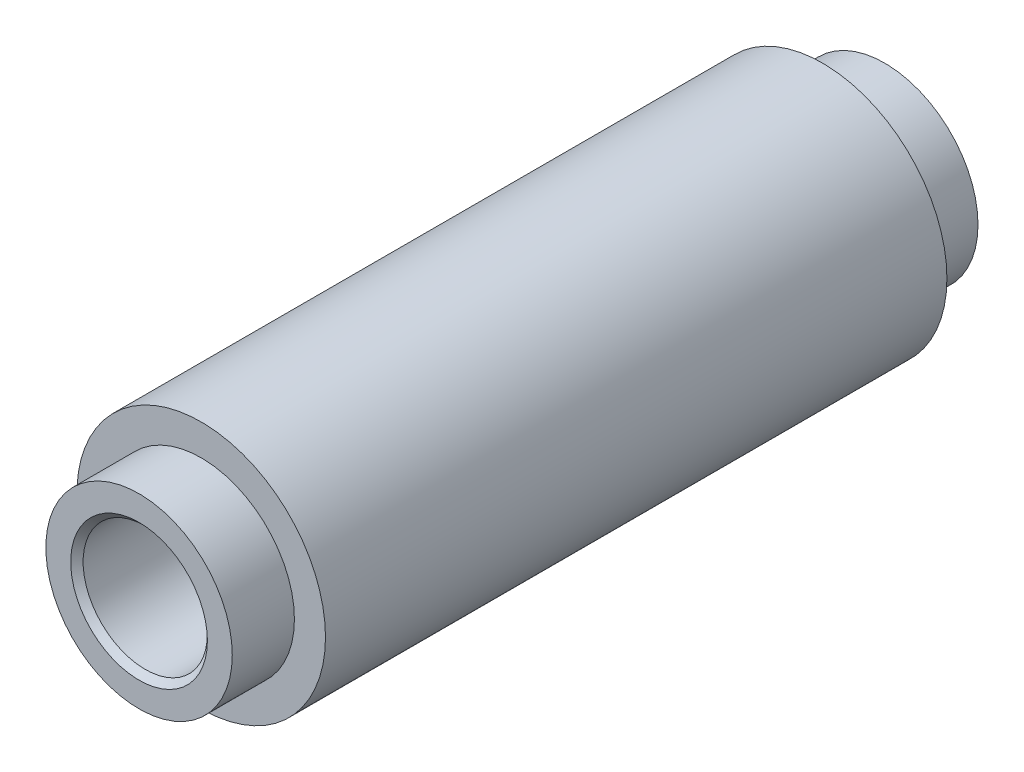
from build123d import *

# Parameters (mm, degrees)
SKETCH1_R           = 4
BOSS_EXTRUDE1_DEPTH = 10
SKETCH2_R           = 3
BOSS_EXTRUDE2_DEPTH = 2
SKETCH3_R           = 2
CUT_EXTRUDE1_DEPTH  = 25
CHAMFER1_SIZE       = 0.2


with BuildPart() as part:
    # Sketch1 → Boss-Extrude1 (new body)
    with BuildSketch(Plane.XY):
        Circle(SKETCH1_R)
    boss_extrude1 = extrude(amount=BOSS_EXTRUDE1_DEPTH)

    # Sketch2 → Boss-Extrude2 (add)
    with BuildSketch(Plane.XY.offset(10)):
        Circle(SKETCH2_R)
    boss_extrude2 = extrude(amount=BOSS_EXTRUDE2_DEPTH)

    # Mirror1: Boss-Extrude1, Boss-Extrude2 across plane
    add(boss_extrude1.mirror(Plane.XY))
    add(boss_extrude2.mirror(Plane.XY))

    # Sketch3 → Cut-Extrude1 (cut, through all)
    with BuildSketch(Plane.XY.offset(12)):
        Circle(SKETCH3_R)
    extrude(amount=-CUT_EXTRUDE1_DEPTH, mode=Mode.SUBTRACT)

    # Chamfer1
    chamfer1_edges = [part.edges().sort_by_distance(p)[0] for p in [
        (-2, 0, -12),
        (-2, 0, 12),
    ]]
    chamfer(chamfer1_edges, length=CHAMFER1_SIZE)


solid = part.part
